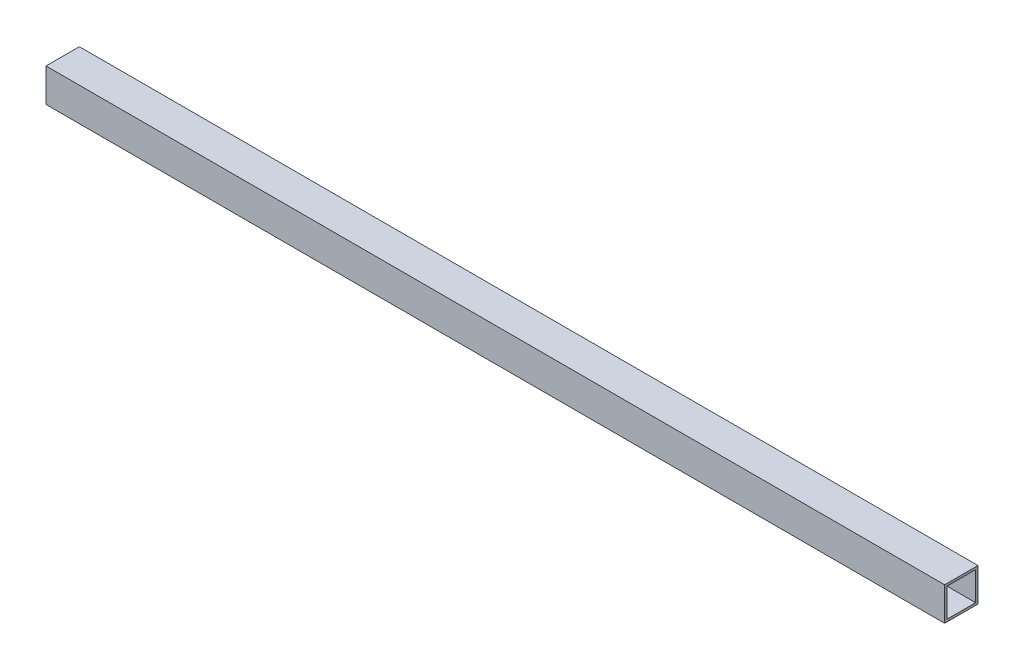
from build123d import *

# Parameters (mm, degrees)
SKETCH1_W           = 44.45
SKETCH1_H           = 44.45
SKETCH1_W_2         = 38.1
SKETCH1_H_2         = 38.1
BOSS_EXTRUDE1_DEPTH = 1196.975


with BuildPart() as part:
    # Sketch1 → Boss-Extrude1 (new body)
    with BuildSketch(Plane(origin=(0, 0, 0), x_dir=(0, 0, -1), z_dir=(1, 0, 0))):
        with Locations((22.225, 22.225)):
            Rectangle(SKETCH1_W, SKETCH1_H)
        with Locations((22.225, 22.225)):
            Rectangle(SKETCH1_W_2, SKETCH1_H_2, mode=Mode.SUBTRACT)
    extrude(amount=BOSS_EXTRUDE1_DEPTH)


solid = part.part
